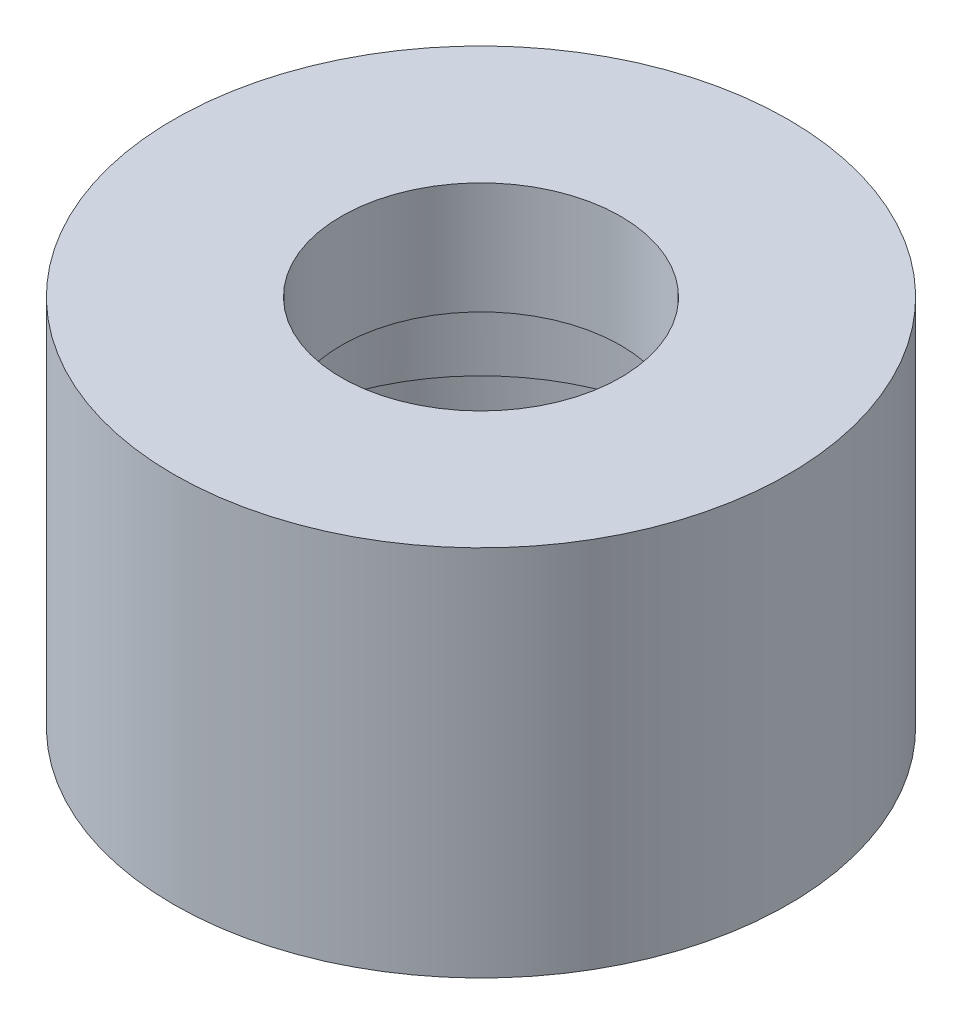
from build123d import *

# Parameters (mm, degrees)
SKETCH1_R               = 16.5
BOSS_EXTRUDE1_DEPTH     = 20
SKETCH3_R               = 7.5
CUT_EXTRUDE2_DEPTH      = 31.732718721
SKETCH7_R               = 11.5
SKETCH7_R_2             = 7.5
CUT_EXTRUDE3_DEPTH      = 14
CUT_EXTRUDE4_REACH      = 32.733
CUT_EXTRUDE4_END_RADIUS = 11.5
CIRPATTERN1_COUNT       = 3


with BuildPart() as part:
    # Sketch1 → Boss-Extrude1 (new body)
    with BuildSketch(Plane(origin=(0, 0, 0), x_dir=(1, 0, 0), z_dir=(0, 1, 0))):
        with Locations(Location((0, 0, 0), (0, 0, 270))):
            Circle(SKETCH1_R)
    extrude(amount=BOSS_EXTRUDE1_DEPTH)

    # Sketch3 → Cut-Extrude2 (cut, through all)
    with BuildSketch(Plane.XZ):
        with Locations(Location((0, 0, 0), (0, 0, 270))):
            Circle(SKETCH3_R)
    extrude(amount=-CUT_EXTRUDE2_DEPTH, mode=Mode.SUBTRACT)

    # Sketch7 → Cut-Extrude3 (cut)
    with BuildSketch(Plane.XZ):
        with Locations(Location((0, 0, 0), (0, 0, 270))):
            Circle(SKETCH7_R)
        with Locations(Location((0, 0, 0), (0, 0, 270))):
            Circle(SKETCH7_R_2, mode=Mode.SUBTRACT)
    extrude(amount=-CUT_EXTRUDE3_DEPTH, mode=Mode.SUBTRACT)

    # Cut-Extrude4: up to this cylinder (the profile starts inside it)
    cut_extrude4_end = Plane(origin=(2, 5.122343, 0), z_dir=(0, -1, 0)) * Cylinder(CUT_EXTRUDE4_END_RADIUS, 89.466, mode=Mode.PRIVATE)
    # Sketch12 → Cut-Extrude4 (cut, up to the surface)
    with BuildSketch(Plane(origin=(0, 0, 0), x_dir=(0, 0, -1), z_dir=(1, 0, 0)), mode=Mode.PRIVATE) as cut_extrude4_sk1:
        Polygon((-8, -0.446060188), (-8, 8.2), (8, 8.2), (8, 4.1), (-3.5, 4.1), (-3.5, -0.446060188), align=None)
    cut_extrude4_tool1 = extrude(cut_extrude4_sk1.sketch, amount=CUT_EXTRUDE4_REACH, mode=Mode.PRIVATE) & cut_extrude4_end
    cut_extrude4 = cut_extrude4_tool1.solids().sort_by_distance((0, 5.122343, 1.366872))[0]
    add(cut_extrude4, mode=Mode.SUBTRACT)

    # CirPattern1: Cut-Extrude4 ×3 about axis
    cirpattern1_axis = Axis((0, 0, 0), (0, 1, 0))
    for i in range(1, CIRPATTERN1_COUNT):
        add(cut_extrude4.rotate(cirpattern1_axis, i * 360 / CIRPATTERN1_COUNT), mode=Mode.SUBTRACT)


solid = part.part
